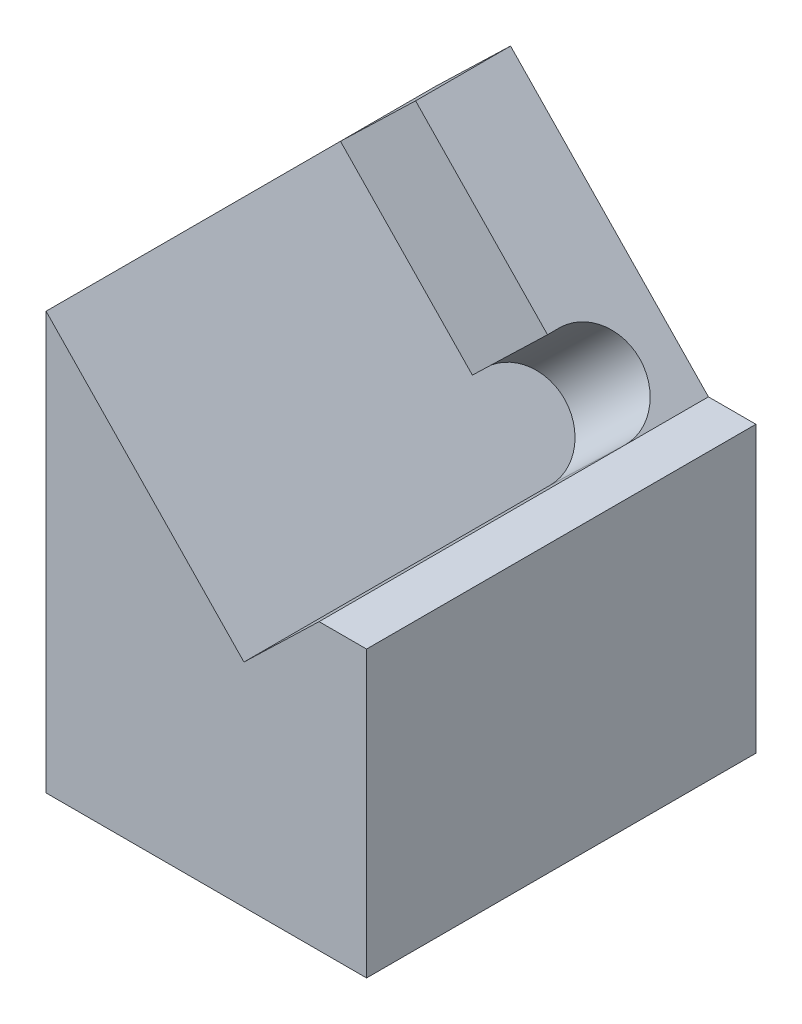
from build123d import *

# Parameters (mm, degrees)
BOSS_EXTRUDE1_DEPTH       = 8.2
CUT_EXTRUDE1_DEPTH        = 2.2
SKETCH3_W                 = 6.75
SKETCH3_H                 = 8.2
BOSS_EXTRUDE2_DEPTH       = 4
F_1_5MM_DOWEL_HOLE1_D     = 1.5
F_1_5MM_DOWEL_HOLE1_DEPTH = 3
F_1_5MM_DOWEL_HOLE1_TIP   = 0.450645464
M2X0_4_TAPPED_HOLE1_D     = 1.6
M2X0_4_TAPPED_HOLE1_DEPTH = 4
M2X0_4_TAPPED_HOLE1_TIP   = 0.480688495


with BuildPart() as part:
    # Sketch1 → Boss-Extrude1 (new body)
    with BuildSketch(Plane.XY):
        Polygon((0, 0), (0, 4.787274917), (1.582547561, 6.315523332), (5.75, 2), (6.75, 2), (6.75, 0), align=None)
    extrude(amount=BOSS_EXTRUDE1_DEPTH)

    # Sketch2 → Cut-Extrude1 (cut)
    with BuildSketch(Plane(origin=(3.97472688, 3.838349131, 0), x_dir=(0, 0, -1), z_dir=(0.7193398, 0.69465837, 0))):
        with BuildLine():
            Line((-8.2, 3.443677383), (-2, 3.443677383))
            Line((-2, 3.443677383), (-2, -0.555606029))
            Line((-2, -0.555606029), (-1.75, -0.555606029))
            ThreePointArc((-1.75, -0.555606029), (-0.75, -1.555606029), (-1.75, -2.555606029))
            Line((-1.75, -2.555606029), (-8.2, -2.555606029))
            Line((-8.2, -2.555606029), (-8.2, 3.443677383))
        make_face()
    extrude(amount=-CUT_EXTRUDE1_DEPTH, mode=Mode.SUBTRACT)

    # Sketch3 → Boss-Extrude2 (add)
    with BuildSketch(Plane.XZ):
        with Locations((3.375, 4.1)):
            Rectangle(SKETCH3_W, SKETCH3_H)
    extrude(amount=BOSS_EXTRUDE2_DEPTH)

    # Ø1.5mm Dowel Hole1
    with Locations(Plane(origin=(0, -4, 0), x_dir=(-1, 0, 0), z_dir=(0, -1, 0))):
        with Locations((-2, -7.1), (-2, -1.1)):
            Hole(F_1_5MM_DOWEL_HOLE1_D / 2, depth=F_1_5MM_DOWEL_HOLE1_DEPTH)
            with Locations((0, 0, -(F_1_5MM_DOWEL_HOLE1_DEPTH + F_1_5MM_DOWEL_HOLE1_TIP / 2))):  # 118° drill point
                Cone(0, F_1_5MM_DOWEL_HOLE1_D / 2, F_1_5MM_DOWEL_HOLE1_TIP, mode=Mode.SUBTRACT)

    # M2x0.4 Tapped Hole1
    with Locations(Plane(origin=(0, -4, 0), x_dir=(-1, 0, 0), z_dir=(0, -1, 0))):
        with Locations((-2, -4.1)):
            Hole(M2X0_4_TAPPED_HOLE1_D / 2, depth=M2X0_4_TAPPED_HOLE1_DEPTH)
            with Locations((0, 0, -(M2X0_4_TAPPED_HOLE1_DEPTH + M2X0_4_TAPPED_HOLE1_TIP / 2))):  # 118° drill point
                Cone(0, M2X0_4_TAPPED_HOLE1_D / 2, M2X0_4_TAPPED_HOLE1_TIP, mode=Mode.SUBTRACT)


solid = part.part
